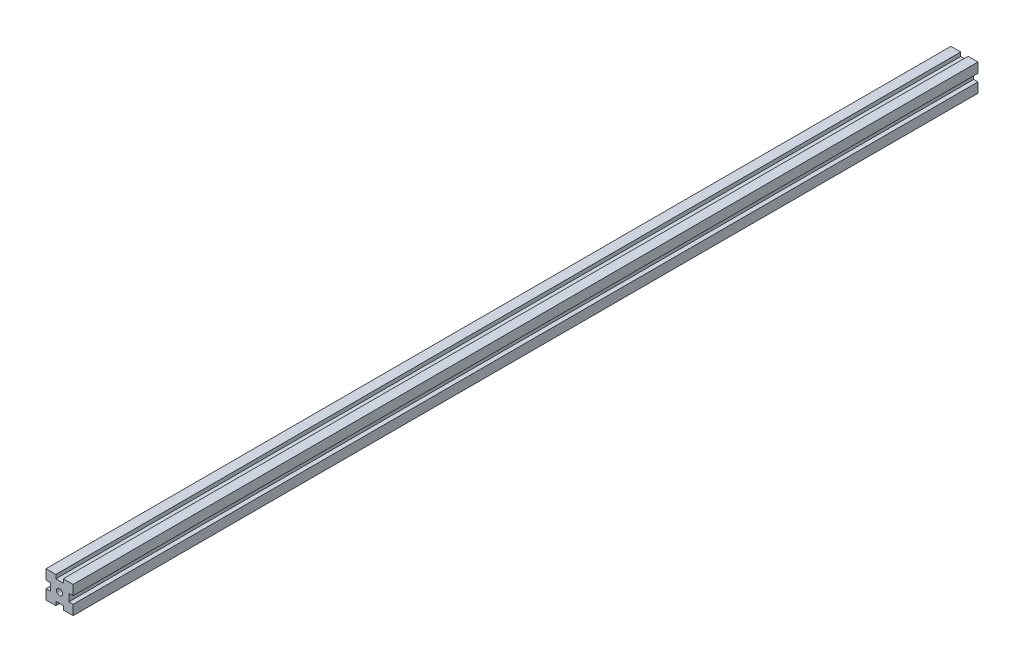
from build123d import *

# Parameters (mm, degrees)
SKETCH_1_R      = 3.4
EXTRUDE_1_DEPTH = 1000


with BuildPart() as part:
    # 草图1 → 凸台-拉伸1 (new body)
    with BuildSketch(Plane.XY):
        Polygon((-11.649484536, 14.484536082), (-0.749484536, 14.484536082), (-0.749484536, 10.213414009), (7.450515464, 10.213414009), (7.450515464, 14.484536082), (18.350515464, 14.484536082), (18.350515464, 3.584536082), (13.594038609, 3.584536082), (13.594038609, -4.615463918), (18.350515464, -4.615463918), (18.350515464, -15.515463918), (7.450515464, -15.515463918), (7.450515464, -11.244341844), (-0.749484536, -11.244341844), (-0.749484536, -15.515463918), (-11.649484536, -15.515463918), (-11.649484536, -4.615463918), (-6.893007681, -4.615463918), (-6.893007681, 3.584536082), (-11.649484536, 3.584536082), align=None)
        with Locations((3.350515464, -0.515463918)):
            Circle(SKETCH_1_R, mode=Mode.SUBTRACT)
    extrude(amount=EXTRUDE_1_DEPTH)


solid = part.part
